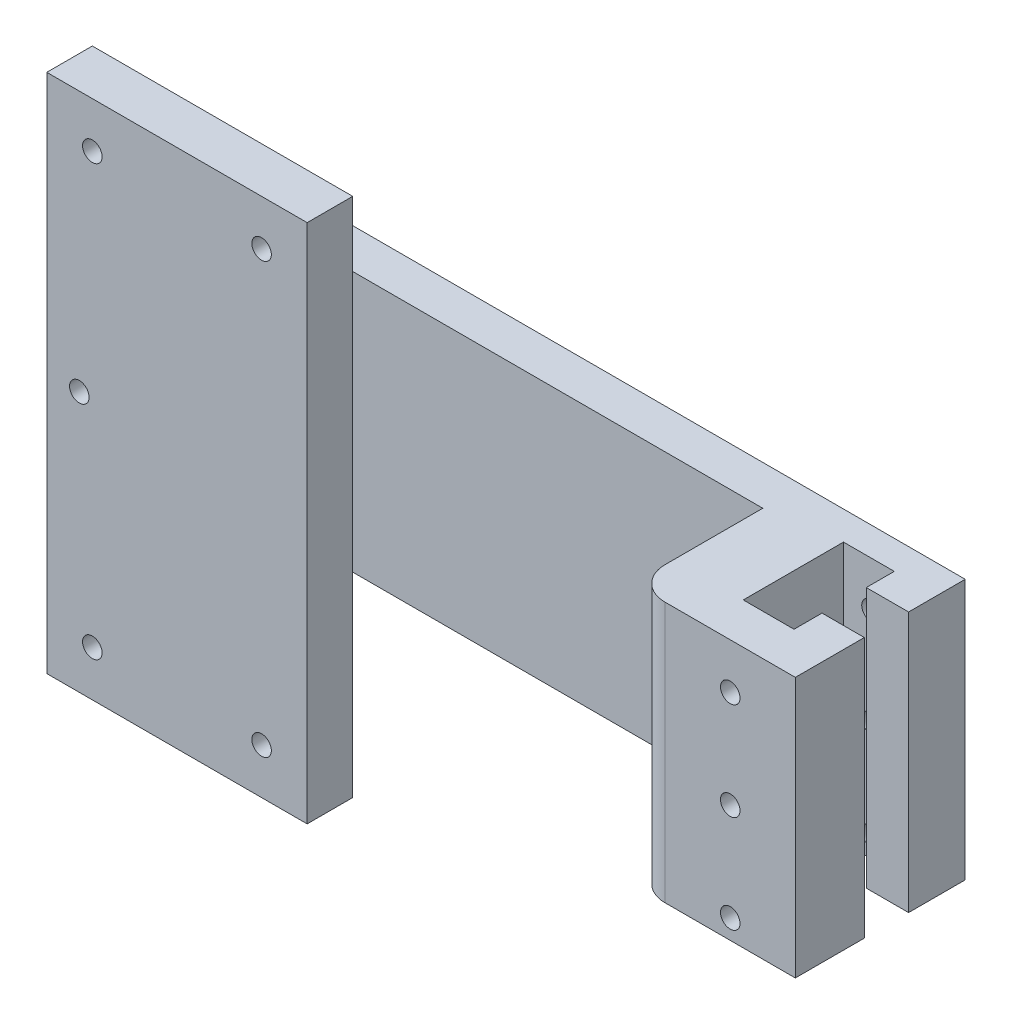
from build123d import *

# Parameters (mm, degrees)
SKETCH1_W           = 110
SKETCH1_H           = 40
BOSS_EXTRUDE1_DEPTH = 26.1
SKETCH2_W           = 6.5
SKETCH2_H           = 6.8
CUT_EXTRUDE1_DEPTH  = 41
SKETCH3_W           = 65
SKETCH3_H           = 40
CUT_EXTRUDE2_DEPTH  = 20
SKETCH5_R           = 1.5
CUT_EXTRUDE3_DEPTH  = 27.1
FILLET1_R           = 5
SKETCH8_W           = 20
SKETCH8_H           = 40
CUT_EXTRUDE4_DEPTH  = 3
SKETCH9_W           = 40
SKETCH9_H           = 80
BOSS_EXTRUDE3_DEPTH = 7
SKETCH10_R          = 1.5
CUT_EXTRUDE5_DEPTH  = 7


with BuildPart() as part:
    # Sketch1 → Boss-Extrude1 (new body)
    with BuildSketch(Plane.XY):
        with Locations((5.766423358, -6.605839416)):
            Rectangle(SKETCH1_W, SKETCH1_H)
    extrude(amount=BOSS_EXTRUDE1_DEPTH)

    # Sketch2 → Cut-Extrude1 (cut, through all)
    with BuildSketch(Plane(origin=(0, 13.394160584, 0), x_dir=(1, 0, 0), z_dir=(0, 1, 0))):
        with Locations((57.516423358, -12.1)):
            Rectangle(SKETCH2_W, SKETCH2_H)
        Polygon((54.266423358, -19.8), (54.266423358, -15.5), (54.266423358, -8.7), (54.266423358, -4.4), (46.466423358, -4.4), (46.466423358, -19.8), align=None)
    extrude(amount=-CUT_EXTRUDE1_DEPTH, mode=Mode.SUBTRACT)

    # Sketch3 → Cut-Extrude2 (cut)
    with BuildSketch(Plane.XY.offset(26.1)):
        with Locations((3.266423358, -6.605839416)):
            Rectangle(SKETCH3_W, SKETCH3_H)
    extrude(amount=-CUT_EXTRUDE2_DEPTH, mode=Mode.SUBTRACT)

    # Sketch5 → Cut-Extrude3 (cut, through all)
    with BuildSketch(Plane.XY.offset(26.1)):
        with Locations((50.766423358, 6.394160584)):
            Circle(SKETCH5_R)
        with Locations((50.766423358, -8.605839416)):
            Circle(SKETCH5_R)
        with Locations((50.766423358, -23.605839416)):
            Circle(SKETCH5_R)
    extrude(amount=-CUT_EXTRUDE3_DEPTH, mode=Mode.SUBTRACT)

    # Fillet1
    fillet1_edges = [part.edges().sort_by_distance(p)[0] for p in [
        (35.766423358, -6.605839416, 26.1),
    ]]
    fillet(fillet1_edges, radius=FILLET1_R)

    # Sketch8 → Cut-Extrude4 (cut)
    with BuildSketch(Plane.XY.offset(26.1)):
        with Locations((-39.233576642, -6.605839416)):
            Rectangle(SKETCH8_W, SKETCH8_H)
    extrude(amount=-CUT_EXTRUDE4_DEPTH, mode=Mode.SUBTRACT)

    # Sketch9 → Boss-Extrude3 (add)
    with BuildSketch(Plane.XY.offset(23.1)):
        with Locations((-37.233576642, -6.605839416)):
            Rectangle(SKETCH9_W, SKETCH9_H)
    extrude(amount=-BOSS_EXTRUDE3_DEPTH)

    # Sketch10 → Cut-Extrude5 (cut)
    with BuildSketch(Plane.XY.offset(23.1)):
        with Locations((-24.233576642, 26.394160584)):
            Circle(SKETCH10_R)
        with Locations((-50.233576642, 26.394160584)):
            Circle(SKETCH10_R)
        with Locations((-52.233576642, -6.605839416)):
            Circle(SKETCH10_R)
        with Locations((-50.233576642, -39.605839416)):
            Circle(SKETCH10_R)
        with Locations((-24.233576642, -39.605839416)):
            Circle(SKETCH10_R)
    extrude(amount=-CUT_EXTRUDE5_DEPTH, mode=Mode.SUBTRACT)


solid = part.part
